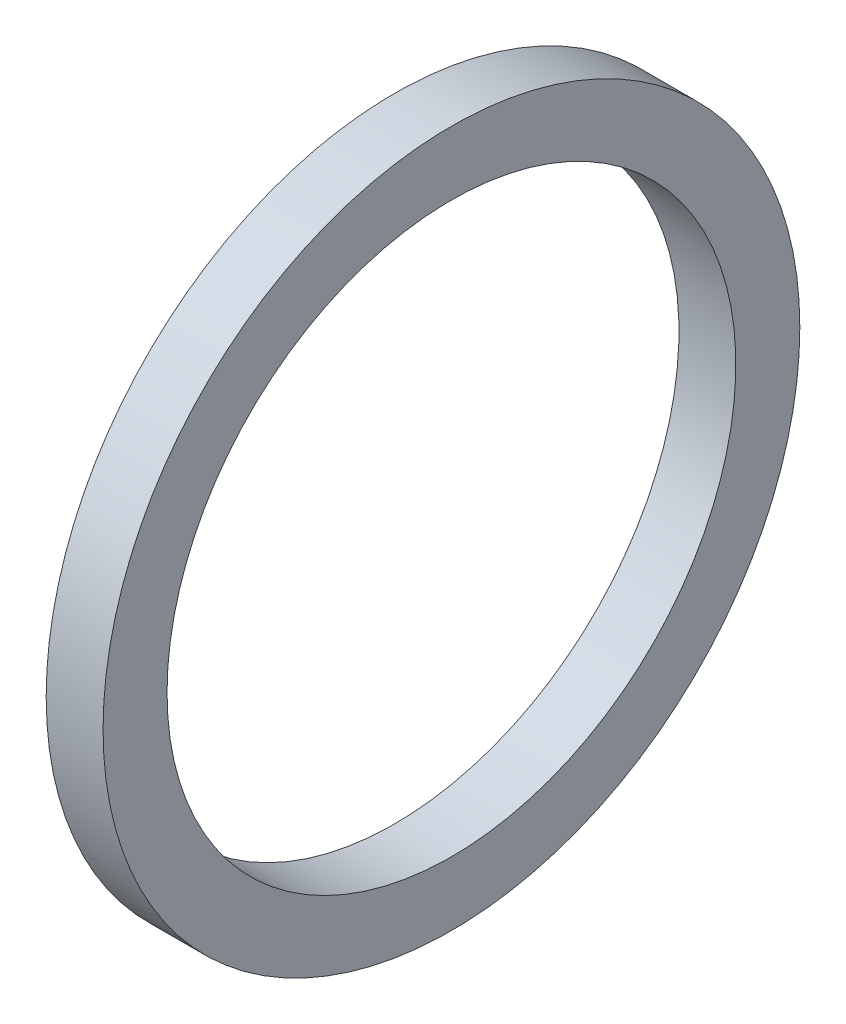
from build123d import *

# Parameters (mm, degrees)
SKETCH1_W = 2.032
SKETCH1_H = 2.286


with BuildPart() as part:
    # Sketch1 → Revolve1 (revolve)
    with BuildSketch(Plane.XY, mode=Mode.PRIVATE) as revolve1_sk:
        with Locations((1.016, -11.303)):
            Rectangle(SKETCH1_W, SKETCH1_H)
    revolve(revolve1_sk.sketch.rotate(Axis((-43.716580756, 0, 0), (1, 0, 0)), 270), axis=Axis((-43.716580756, 0, 0), (1, 0, 0)))  # turned: the seam where the file's is


solid = part.part
